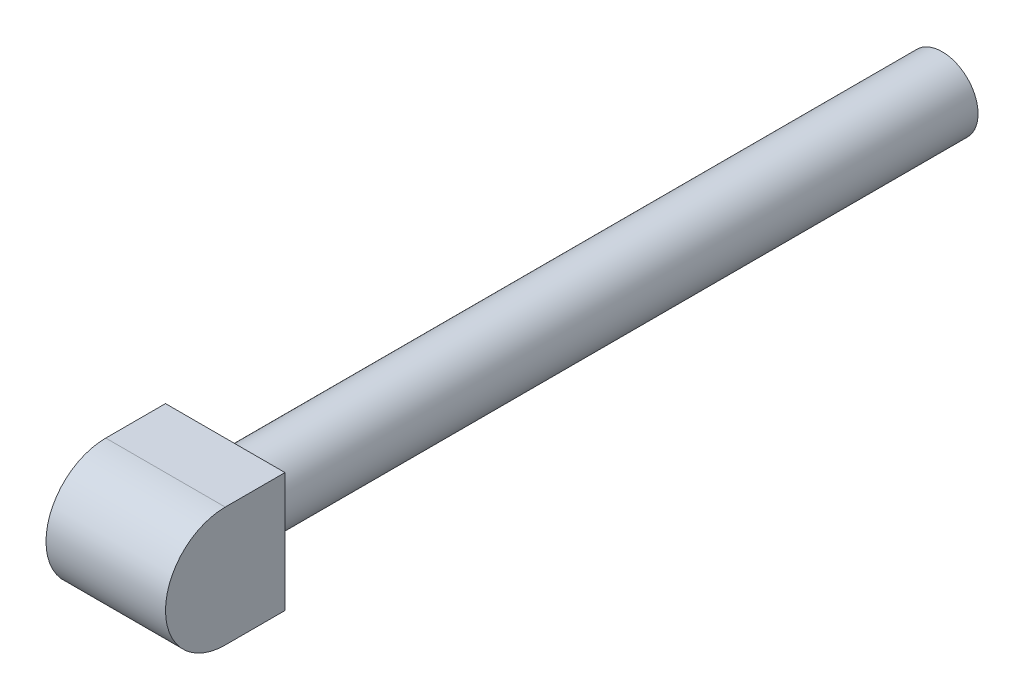
from build123d import *

# Parameters (mm, degrees)
SKETCH_1_W          = 20
SKETCH_1_H          = 20
EXTRUDE_1_DEPTH     = 20
SKETCH_2_R          = 6
EXTRUDE_2_DEPTH     = 120
CUT_EXTRUDE_1_DEPTH = 70


with BuildPart() as part:
    # 草图1 → 凸台-拉伸1 (new body)
    with BuildSketch(Plane.XY):
        Rectangle(SKETCH_1_W, SKETCH_1_H)
    extrude(amount=EXTRUDE_1_DEPTH)

    # 草图2 → 凸台-拉伸2 (add)
    with BuildSketch(Plane(origin=(0, 0, 0), x_dir=(-1, 0, 0), z_dir=(0, 0, -1))):
        Circle(SKETCH_2_R)
    extrude(amount=EXTRUDE_2_DEPTH)

    # 草图3 → 切除-拉伸1 (cut)
    with BuildSketch(Plane(origin=(10, 0, 0), x_dir=(0, 0, -1), z_dir=(1, 0, 0))):
        with BuildLine():
            Line((-10, 10), (-23.053143475, 10))
            Line((-23.053143475, 10), (-23.053143475, -10))
            Line((-23.053143475, -10), (-10, -10))
            ThreePointArc((-10, -10), (-20, 0), (-10, 10))
        make_face()
    extrude(amount=-CUT_EXTRUDE_1_DEPTH, mode=Mode.SUBTRACT)


solid = part.part
